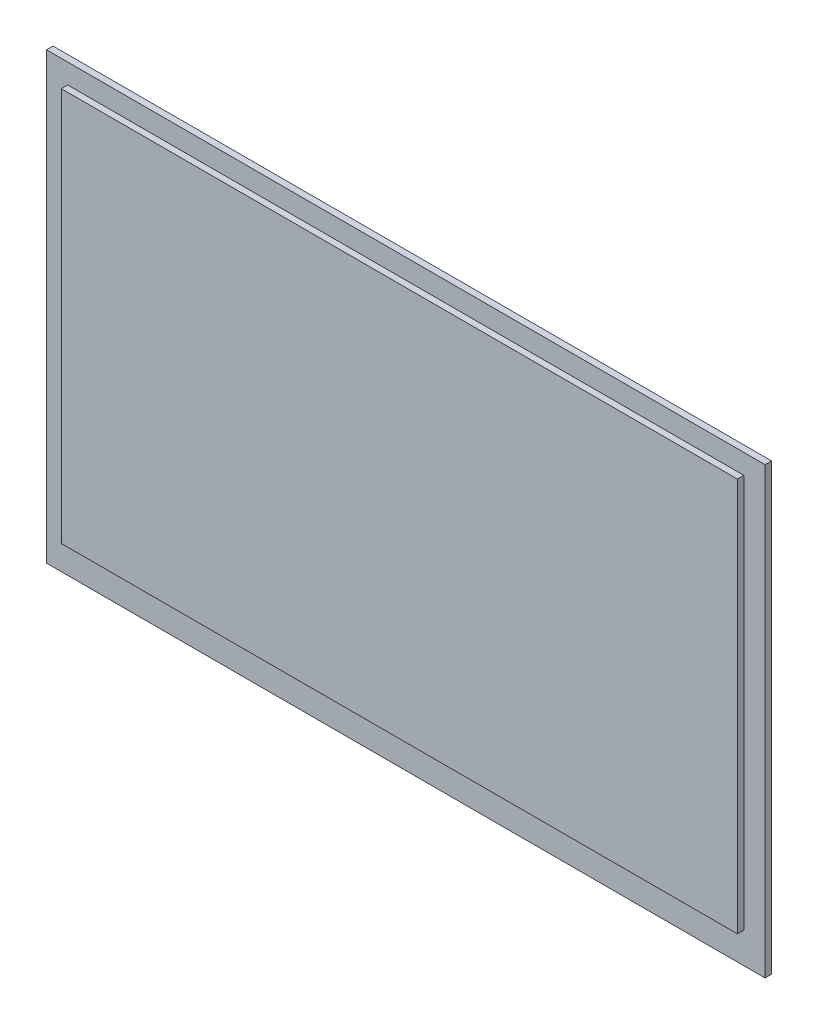
from build123d import *

# Parameters (mm, degrees)
SKETCH1_W           = 104.9
SKETCH1_H           = 64.9
BOSS_EXTRUDE1_DEPTH = 0.95
SKETCH2_W           = 98.7
SKETCH2_H           = 57.5
BOSS_EXTRUDE2_DEPTH = 0.935


with BuildPart() as part:
    # Sketch1 → Boss-Extrude1 (new body)
    with BuildSketch(Plane.XY):
        Rectangle(SKETCH1_W, SKETCH1_H)
    extrude(amount=BOSS_EXTRUDE1_DEPTH)

    # Sketch2 → Boss-Extrude2 (add)
    with BuildSketch(Plane.XY.offset(0.95)):
        with Locations((0, 0.8)):
            Rectangle(SKETCH2_W, SKETCH2_H)
    extrude(amount=BOSS_EXTRUDE2_DEPTH)


solid = part.part
